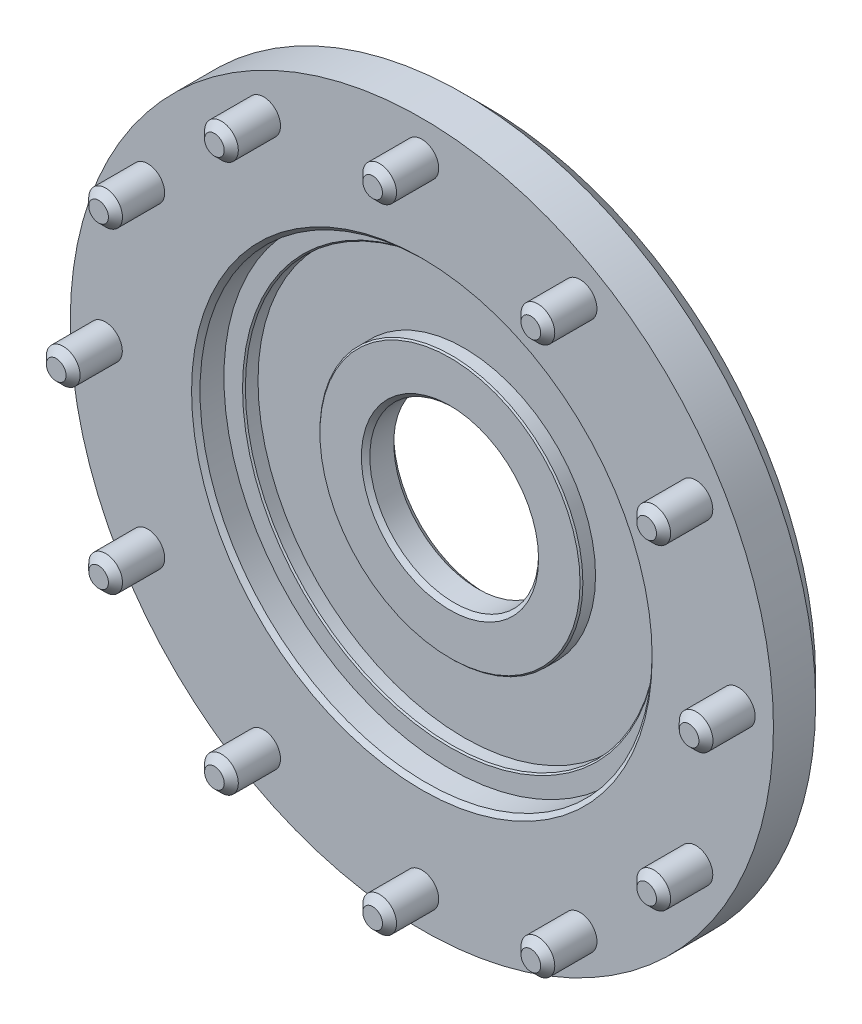
from build123d import *

# Parameters (mm, degrees)
SKETCH1_R                    = 50
BOSS_EXTRUDE1_DEPTH          = 9
SKETCH2_R                    = 2.4
BOSS_EXTRUDE2_DEPTH          = 7
CHAMFER1_SIZE                = 1
CIRPATTERN1_COUNT            = 12
CHAMFER1_OF_CIRPATTERN1_SIZE = 1
SKETCH3_R                    = 32.15
CUT_EXTRUDE1_DEPTH           = 4
SKETCH4_R                    = 12
CUT_EXTRUDE2_DEPTH           = 10
CHAMFER2_SIZE                = 0.6
SKETCH5_R                    = 29.3
SKETCH5_R_2                  = 18.7
CUT_EXTRUDE3_DEPTH           = 2
CHAMFER3_SIZE                = 0.2
CHAMFER4_SIZE                = 3
CHAMFER5_SIZE                = 1
CHAMFER6_SIZE                = 0.6


with BuildPart() as part:
    # Sketch1 → Boss-Extrude1 (new body)
    with BuildSketch(Plane.XY):
        Circle(SKETCH1_R)
    extrude(amount=-BOSS_EXTRUDE1_DEPTH)

    # Sketch2 → Boss-Extrude2 (add)
    with BuildSketch(Plane.XY):
        with Locations((45, 0)):
            Circle(SKETCH2_R)
    boss_extrude2 = extrude(amount=BOSS_EXTRUDE2_DEPTH)

    # Chamfer1
    chamfer1_edges = [part.edges().sort_by_distance(p)[0] for p in [
        (42.6, 0, 7),
    ]]
    chamfer(chamfer1_edges, length=CHAMFER1_SIZE)

    # CirPattern1: Boss-Extrude2 ×12 about axis
    cirpattern1_axis = Axis((0, 0, 0), (0, 0, 1))
    for i in range(1, CIRPATTERN1_COUNT):
        add(boss_extrude2.rotate(cirpattern1_axis, i * 360 / CIRPATTERN1_COUNT))

    # Chamfer1 of CirPattern1
    chamfer1_of_cirpattern1_edges = [part.edges().sort_by_distance(p)[0] for p in [
        (36.892682201, 21.3, 7),
        (21.3, 36.892682201, 7),
        (0, 42.6, 7),
        (-21.3, 36.892682201, 7),
        (-36.892682201, 21.3, 7),
        (-42.6, 0, 7),
        (-36.892682201, -21.3, 7),
        (-21.3, -36.892682201, 7),
        (0, -42.6, 7),
        (21.3, -36.892682201, 7),
        (36.892682201, -21.3, 7),
    ]]
    chamfer(chamfer1_of_cirpattern1_edges, length=CHAMFER1_OF_CIRPATTERN1_SIZE)

    # Sketch3 → Cut-Extrude1 (cut)
    with BuildSketch(Plane.XY):
        Circle(SKETCH3_R)
    extrude(amount=-CUT_EXTRUDE1_DEPTH, mode=Mode.SUBTRACT)

    # Sketch4 → Cut-Extrude2 (cut, through all)
    with BuildSketch(Plane.XY):
        Circle(SKETCH4_R)
    extrude(amount=-CUT_EXTRUDE2_DEPTH, mode=Mode.SUBTRACT)

    # Chamfer2
    chamfer2_edges = [part.edges().sort_by_distance(p)[0] for p in [
        (-32.15, 0, 0),
    ]]
    chamfer(chamfer2_edges, length=CHAMFER2_SIZE)

    # Sketch5 → Cut-Extrude3 (cut)
    with BuildSketch(Plane.XY.offset(-4)):
        Circle(SKETCH5_R)
        Circle(SKETCH5_R_2, mode=Mode.SUBTRACT)
    extrude(amount=-CUT_EXTRUDE3_DEPTH, mode=Mode.SUBTRACT)

    # Chamfer3
    chamfer3_edges = [part.edges().sort_by_distance(p)[0] for p in [
        (-29.3, 0, -4),
        (-18.7, 0, -4),
    ]]
    chamfer(chamfer3_edges, length=CHAMFER3_SIZE)

    # Chamfer4
    chamfer4_edges = [part.edges().sort_by_distance(p)[0] for p in [
        (-50, 0, -9),
    ]]
    chamfer(chamfer4_edges, length=CHAMFER4_SIZE)

    # Chamfer5
    chamfer5_edges = [part.edges().sort_by_distance(p)[0] for p in [
        (-12, 0, -9),
    ]]
    chamfer(chamfer5_edges, length=CHAMFER5_SIZE)

    # Chamfer6
    chamfer6_edges = [part.edges().sort_by_distance(p)[0] for p in [
        (-12, 0, -4),
    ]]
    chamfer(chamfer6_edges, length=CHAMFER6_SIZE)


solid = part.part
